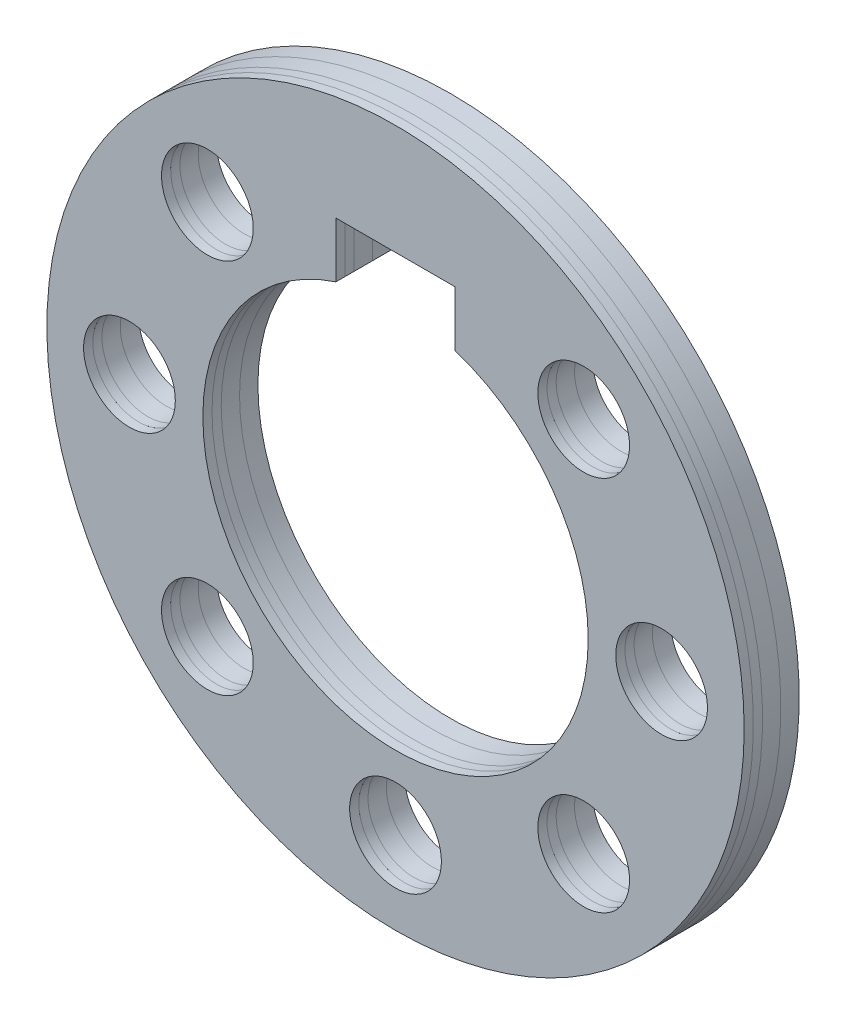
from build123d import *

# Parameters (mm, degrees)
SKETCH_1_R                       = 19
EXTRUDE_1_DEPTH                  = 5
SKETCH_2_R                       = 2.5
CUT_EXTRUDE_2_DEPTH              = 28.331300737
SPLIT_BODIES_1_SURFACE_1_1_BACK  = 54.972
SPLIT_BODIES_1_SURFACE_1_1_DEPTH = 109.944
SPLIT_BODIES_1_SURFACE_1_2_BACK  = 54.972
SPLIT_BODIES_1_SURFACE_1_2_DEPTH = 109.944
SPLIT_BODIES_1_SURFACE_2_3_BACK  = 54.972
SPLIT_BODIES_1_SURFACE_2_3_DEPTH = 109.944
SPLIT_BODIES_1_SURFACE_2_4_BACK  = 54.972
SPLIT_BODIES_1_SURFACE_2_4_DEPTH = 109.944
SPLIT_BODIES_1_SURFACE_3_5_BACK  = 54.972
SPLIT_BODIES_1_SURFACE_3_5_DEPTH = 109.944
SPLIT_BODIES_1_SURFACE_3_6_BACK  = 54.972
SPLIT_BODIES_1_SURFACE_3_6_DEPTH = 109.944
SPLIT_BODIES_1_SURFACE_4_7_BACK  = 54.972
SPLIT_BODIES_1_SURFACE_4_7_DEPTH = 109.944
SPLIT_BODIES_1_SURFACE_4_8_BACK  = 54.972
SPLIT_BODIES_1_SURFACE_4_8_DEPTH = 109.944


with BuildPart() as part:
    # Эскиз1 → Вытянуть1 (new body)
    with BuildSketch(Plane.XY):
        Circle(SKETCH_1_R)
        with BuildLine():
            Line((-3.25, 13), (3.25, 13))
            Line((3.25, 13), (3.25, 9.984362774))
            ThreePointArc((3.25, 9.984362774), (0, -10.5), (-3.25, 9.984362774))
            Line((-3.25, 9.984362774), (-3.25, 13))
        make_face(mode=Mode.SUBTRACT)
    extrude(amount=EXTRUDE_1_DEPTH)

    # Эскиз2 → Вытянуть2 (cut, through all)
    with BuildSketch(Plane.XY.offset(5)):
        with Locations((10.253048327, 10.253048327)):
            Circle(SKETCH_2_R)
        with Locations((14.5, 0)):
            Circle(SKETCH_2_R)
        with Locations((10.253048327, -10.253048327)):
            Circle(SKETCH_2_R)
        with Locations((0, -14.5)):
            Circle(SKETCH_2_R)
        with Locations((-10.253048327, -10.253048327)):
            Circle(SKETCH_2_R)
        with Locations((-14.5, 0)):
            Circle(SKETCH_2_R)
        with Locations((-10.253048327, 10.253048327)):
            Circle(SKETCH_2_R)
    extrude(amount=-CUT_EXTRUDE_2_DEPTH, mode=Mode.SUBTRACT)


with BuildPart() as body_2:
    # Split Bodies 1: the piece behind the surface
    add(part.part)
    # Split Bodies 1 surface 1: a surface, the sketch's curves swept straight by 109.944 mm
    with BuildLine(Plane(origin=(0, 0, 0), x_dir=(0, 0, -1), z_dir=(1, 0, 0)).offset(-SPLIT_BODIES_1_SURFACE_1_1_BACK), mode=Mode.PRIVATE) as split_bodies_1_surface_1_1_path:
        Line((-4.5, 19), (-4.5, -19))
    split_bodies_1_surface_1_1 = Shell.extrude(split_bodies_1_surface_1_1_path.wire(), (1 * SPLIT_BODIES_1_SURFACE_1_1_DEPTH, 0 * SPLIT_BODIES_1_SURFACE_1_1_DEPTH, 0 * SPLIT_BODIES_1_SURFACE_1_1_DEPTH))
    split(bisect_by=split_bodies_1_surface_1_1, keep=Keep.BOTTOM)


with BuildPart() as part_1:
    add(part.part)

    # Split Bodies 1: split by a surface, the side it looks to stays
    # Split Bodies 1 surface 1: a surface, the sketch's curves swept straight by 109.944 mm
    with BuildLine(Plane(origin=(0, 0, 0), x_dir=(0, 0, -1), z_dir=(1, 0, 0)).offset(-SPLIT_BODIES_1_SURFACE_1_2_BACK), mode=Mode.PRIVATE) as split_bodies_1_surface_1_2_path:
        Line((-4.5, 19), (-4.5, -19))
    split_bodies_1_surface_1_2 = Shell.extrude(split_bodies_1_surface_1_2_path.wire(), (1 * SPLIT_BODIES_1_SURFACE_1_2_DEPTH, 0 * SPLIT_BODIES_1_SURFACE_1_2_DEPTH, 0 * SPLIT_BODIES_1_SURFACE_1_2_DEPTH))
    split(bisect_by=split_bodies_1_surface_1_2, keep=Keep.TOP)


with BuildPart() as body_3:
    # Split Bodies 1 2: the piece behind the surface
    add(part_1.part)
    # Split Bodies 1 surface 2: a surface, the sketch's curves swept straight by 109.944 mm
    with BuildLine(Plane(origin=(0, 0, 0), x_dir=(0, 0, -1), z_dir=(1, 0, 0)).offset(-SPLIT_BODIES_1_SURFACE_2_3_BACK), mode=Mode.PRIVATE) as split_bodies_1_surface_2_3_path:
        Line((-4, 19), (-4, -19))
    split_bodies_1_surface_2_3 = Shell.extrude(split_bodies_1_surface_2_3_path.wire(), (1 * SPLIT_BODIES_1_SURFACE_2_3_DEPTH, 0 * SPLIT_BODIES_1_SURFACE_2_3_DEPTH, 0 * SPLIT_BODIES_1_SURFACE_2_3_DEPTH))
    split(bisect_by=split_bodies_1_surface_2_3, keep=Keep.BOTTOM)


with BuildPart() as part_2:
    add(part_1.part)

    # Split Bodies 1 2: split by a surface, the side it looks to stays
    # Split Bodies 1 surface 2: a surface, the sketch's curves swept straight by 109.944 mm
    with BuildLine(Plane(origin=(0, 0, 0), x_dir=(0, 0, -1), z_dir=(1, 0, 0)).offset(-SPLIT_BODIES_1_SURFACE_2_4_BACK), mode=Mode.PRIVATE) as split_bodies_1_surface_2_4_path:
        Line((-4, 19), (-4, -19))
    split_bodies_1_surface_2_4 = Shell.extrude(split_bodies_1_surface_2_4_path.wire(), (1 * SPLIT_BODIES_1_SURFACE_2_4_DEPTH, 0 * SPLIT_BODIES_1_SURFACE_2_4_DEPTH, 0 * SPLIT_BODIES_1_SURFACE_2_4_DEPTH))
    split(bisect_by=split_bodies_1_surface_2_4, keep=Keep.TOP)


with BuildPart() as body_4_2:
    # Split Bodies 1 3: the piece behind the surface
    add(part_2.part)
    # Split Bodies 1 surface 3: a surface, the sketch's curves swept straight by 109.944 mm
    with BuildLine(Plane(origin=(0, 0, 0), x_dir=(0, 0, -1), z_dir=(1, 0, 0)).offset(-SPLIT_BODIES_1_SURFACE_3_5_BACK), mode=Mode.PRIVATE) as split_bodies_1_surface_3_5_path:
        Line((-3, 19), (-3, -19))
    split_bodies_1_surface_3_5 = Shell.extrude(split_bodies_1_surface_3_5_path.wire(), (1 * SPLIT_BODIES_1_SURFACE_3_5_DEPTH, 0 * SPLIT_BODIES_1_SURFACE_3_5_DEPTH, 0 * SPLIT_BODIES_1_SURFACE_3_5_DEPTH))
    split(bisect_by=split_bodies_1_surface_3_5, keep=Keep.BOTTOM)


with BuildPart() as part_3:
    add(part_2.part)

    # Split Bodies 1 3: split by a surface, the side it looks to stays
    # Split Bodies 1 surface 3: a surface, the sketch's curves swept straight by 109.944 mm
    with BuildLine(Plane(origin=(0, 0, 0), x_dir=(0, 0, -1), z_dir=(1, 0, 0)).offset(-SPLIT_BODIES_1_SURFACE_3_6_BACK), mode=Mode.PRIVATE) as split_bodies_1_surface_3_6_path:
        Line((-3, 19), (-3, -19))
    split_bodies_1_surface_3_6 = Shell.extrude(split_bodies_1_surface_3_6_path.wire(), (1 * SPLIT_BODIES_1_SURFACE_3_6_DEPTH, 0 * SPLIT_BODIES_1_SURFACE_3_6_DEPTH, 0 * SPLIT_BODIES_1_SURFACE_3_6_DEPTH))
    split(bisect_by=split_bodies_1_surface_3_6, keep=Keep.TOP)


with BuildPart() as body_5_2:
    # Split Bodies 1 4: the piece behind the surface
    add(part_3.part)
    # Split Bodies 1 surface 4: a surface, the sketch's curves swept straight by 109.944 mm
    with BuildLine(Plane(origin=(0, 0, 0), x_dir=(0, 0, -1), z_dir=(1, 0, 0)).offset(-SPLIT_BODIES_1_SURFACE_4_7_BACK), mode=Mode.PRIVATE) as split_bodies_1_surface_4_7_path:
        Line((-2, 19), (-2, -19))
    split_bodies_1_surface_4_7 = Shell.extrude(split_bodies_1_surface_4_7_path.wire(), (1 * SPLIT_BODIES_1_SURFACE_4_7_DEPTH, 0 * SPLIT_BODIES_1_SURFACE_4_7_DEPTH, 0 * SPLIT_BODIES_1_SURFACE_4_7_DEPTH))
    split(bisect_by=split_bodies_1_surface_4_7, keep=Keep.BOTTOM)


with BuildPart() as part_4:
    add(part_3.part)

    # Split Bodies 1 4: split by a surface, the side it looks to stays
    # Split Bodies 1 surface 4: a surface, the sketch's curves swept straight by 109.944 mm
    with BuildLine(Plane(origin=(0, 0, 0), x_dir=(0, 0, -1), z_dir=(1, 0, 0)).offset(-SPLIT_BODIES_1_SURFACE_4_8_BACK), mode=Mode.PRIVATE) as split_bodies_1_surface_4_8_path:
        Line((-2, 19), (-2, -19))
    split_bodies_1_surface_4_8 = Shell.extrude(split_bodies_1_surface_4_8_path.wire(), (1 * SPLIT_BODIES_1_SURFACE_4_8_DEPTH, 0 * SPLIT_BODIES_1_SURFACE_4_8_DEPTH, 0 * SPLIT_BODIES_1_SURFACE_4_8_DEPTH))
    split(bisect_by=split_bodies_1_surface_4_8, keep=Keep.TOP)


solid = Compound([body_2.part, body_3.part, body_4_2.part, body_5_2.part])
